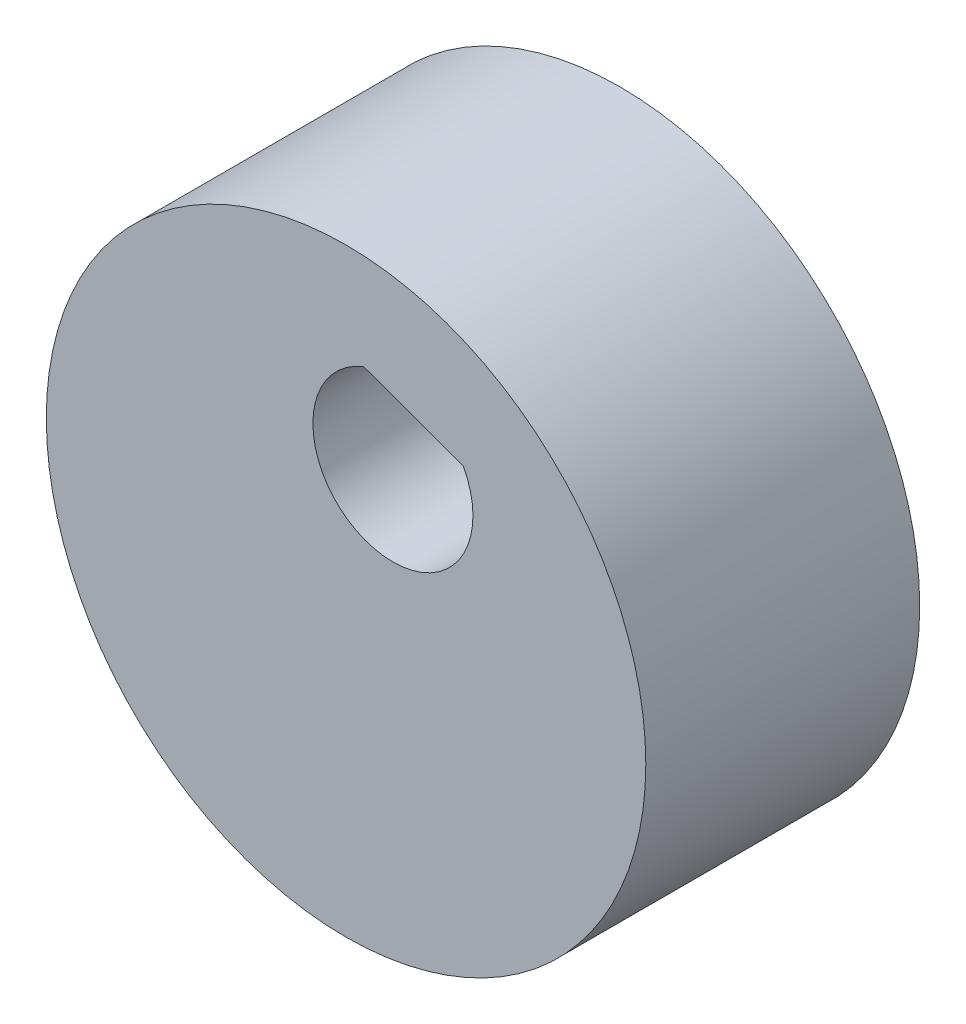
from build123d import *

# Parameters (mm, degrees)
BOSS_EXTRUDE1_START = 53.740316
SKETCH1_R           = 9.85
BOSS_EXTRUDE1_DEPTH = 9
CUT_EXTRUDE1_START  = -9
SKETCH2_R           = 2.63
CUT_EXTRUDE1_DEPTH  = 1


with BuildPart() as part:
    # Sketch1 → Boss-Extrude1 (new body)
    with BuildSketch(Plane.XY.offset(BOSS_EXTRUDE1_START)):
        with Locations((-21.682123493, -41.352707657)):
            Circle(SKETCH1_R)
        with BuildLine():
            Line((-21.105209467, -34.677075087), (-17.830791495, -35.869629886))
            ThreePointArc((-17.830791495, -35.869629886), (-21.042183766, -39.595614277), (-21.105209467, -34.677075087))
        make_face(mode=Mode.SUBTRACT)
    extrude(amount=BOSS_EXTRUDE1_DEPTH)

    # Sketch2 → Cut-Extrude1 (cut)
    with BuildSketch(Plane.XY.offset(62.740315649).offset(CUT_EXTRUDE1_START)):
        with Locations((-20.142161583, -37.124408079)):
            Circle(SKETCH2_R)
    extrude(amount=CUT_EXTRUDE1_DEPTH, mode=Mode.SUBTRACT)


solid = part.part
